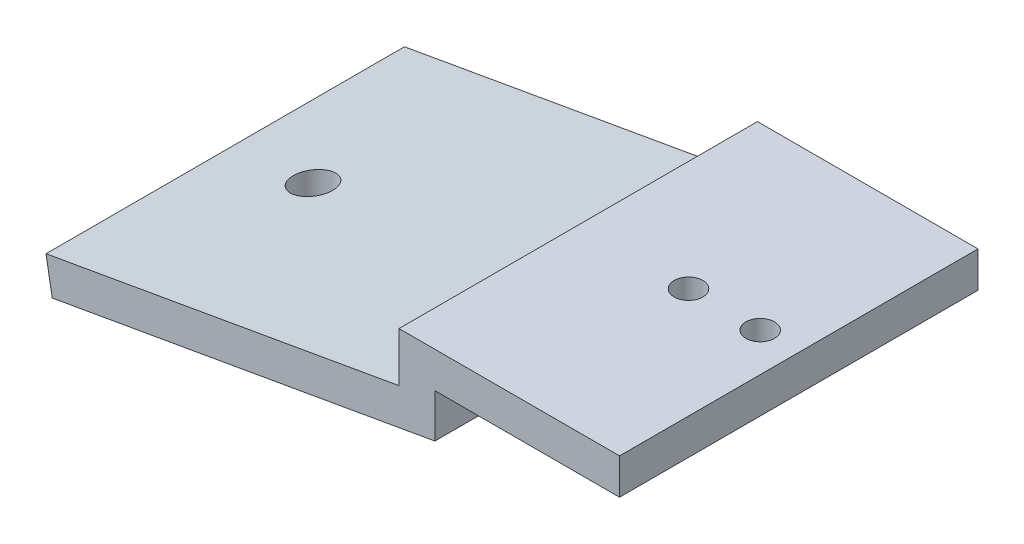
from build123d import *

# Parameters (mm, degrees)
BOSS_EXTRUDE1_DEPTH = 50
SKETCH2_R           = 2.75
SKETCH2_R_2         = 2
CUT_EXTRUDE1_DEPTH  = 50


with BuildPart() as part:
    # Sketch1 → Boss-Extrude1 (new body)
    with BuildSketch(Plane.XY):
        Polygon((0, 2.5), (-30.759612349, 2.5), (-30.759612349, -4.397890897), (-80, -13.08029978), (-79.131759112, -18.004338545), (-25.759612349, -8.593389053), (-25.759612349, -2.5), (0, -2.5), align=None)
    extrude(amount=BOSS_EXTRUDE1_DEPTH)

    # Sketch2 → Cut-Extrude1 (cut)
    with BuildSketch(Plane(origin=(0, 2.5, 0), x_dir=(1, 0, 0), z_dir=(0, 1, 0))):
        with Locations((-67.759612349, -25)):
            Circle(SKETCH2_R)
        with Locations((-15.379806175, -25)):
            Circle(SKETCH2_R_2)
        with Locations((-5.379806175, -25)):
            Circle(SKETCH2_R_2)
    extrude(amount=-CUT_EXTRUDE1_DEPTH, mode=Mode.SUBTRACT)


solid = part.part
